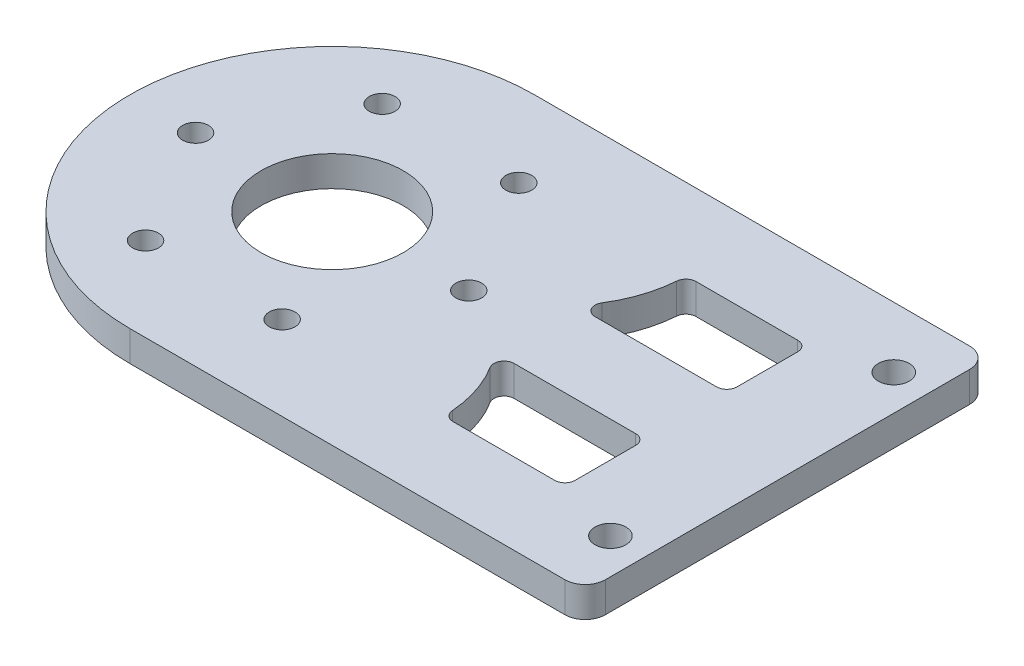
from build123d import *

# Parameters (mm, degrees)
SKETCH_1_R          = 20
SKETCH_1_W          = 45
SKETCH_1_H          = 40
EXTRUDE_1_DEPTH     = 3
SKETCH_3_R          = 1.275
CUT_EXTRUDE_3_DEPTH = 4
SKETCH_6_R          = 7.025
CUT_EXTRUDE_6_DEPTH = 4
FILLET_1_R          = 2
SKETCH_7_R          = 1.525
CUT_EXTRUDE_7_DEPTH = 4
CUT_EXTRUDE_8_DEPTH = 10


with BuildPart() as part:
    # 草图1 → 凸台-拉伸1 (new body)
    with BuildSketch(Plane(origin=(0, 0, 0), x_dir=(1, 0, 0), z_dir=(0, 1, 0))):
        with Locations((-22.5, 0)):
            Circle(SKETCH_1_R)
        Rectangle(SKETCH_1_W, SKETCH_1_H)
    extrude(amount=EXTRUDE_1_DEPTH)

    # 草图3 → 切除-拉伸3 (cut, through all)
    with BuildSketch(Plane(origin=(0, 0, 0), x_dir=(1, 0, 0), z_dir=(0, 1, 0))):
        with Locations((-36, 0)):
            Circle(SKETCH_3_R)
        with Locations((-29.25, 11.691342951)):
            Circle(SKETCH_3_R)
        with Locations((-15.75, 11.691342951)):
            Circle(SKETCH_3_R)
        with Locations((-9, 0)):
            Circle(SKETCH_3_R)
        with Locations((-15.75, -11.691342951)):
            Circle(SKETCH_3_R)
        with Locations((-29.25, -11.691342951)):
            Circle(SKETCH_3_R)
    extrude(amount=CUT_EXTRUDE_3_DEPTH, mode=Mode.SUBTRACT)

    # 草图6 → 切除-拉伸6 (cut, through all)
    with BuildSketch(Plane(origin=(0, 3, 0), x_dir=(1, 0, 0), z_dir=(0, 1, 0))):
        with Locations((-22.5, 0)):
            Circle(SKETCH_6_R)
    extrude(amount=-CUT_EXTRUDE_6_DEPTH, mode=Mode.SUBTRACT)

    # 圆角1
    fillet_1_edges = [part.edges().sort_by_distance(p)[0] for p in [
        (22.5, 1.5, -20),
        (22.5, 1.5, 20),
    ]]
    fillet(fillet_1_edges, radius=FILLET_1_R)

    # 草图7 → 切除-拉伸7 (cut, through all)
    with BuildSketch(Plane(origin=(0, 3, 0), x_dir=(1, 0, 0), z_dir=(0, 1, 0))):
        with Locations((19, -14)):
            Circle(SKETCH_7_R)
        with Locations((19, 14)):
            Circle(SKETCH_7_R)
    extrude(amount=-CUT_EXTRUDE_7_DEPTH, mode=Mode.SUBTRACT)

    # 草图8 → 切除-拉伸8 (cut)
    with BuildSketch(Plane(origin=(0, 3, 0), x_dir=(1, 0, 0), z_dir=(0, 1, 0))):
        with BuildLine():
            Line((-0.51493536, -4.000000002), (11.500000002, -4.000000002))
            ThreePointArc((11.500000002, -4.000000002), (12.207106783, -4.29289322), (12.500000002, -5.000000002))
            Line((12.500000002, -5.000000002), (12.500000002, -11.000000002))
            ThreePointArc((12.500000002, -11.000000002), (12.207106783, -11.707106783), (11.500000002, -12.000000002))
            Line((11.500000002, -12.000000002), (1.461970397, -12.000000002))
            ThreePointArc((1.461970397, -12.000000002), (0.782245955, -11.733467577), (0.464858721, -11.075949369))
            ThreePointArc((0.464858721, -11.075949369), (-0.111079243, -8.192615452), (-1.361902294, -5.531645571))
            ThreePointArc((-1.361902294, -5.531645571), (-1.390048372, -4.516081398), (-0.51493536, -4.000000002))
        make_face()
    cut_extrude_8 = extrude(amount=-CUT_EXTRUDE_8_DEPTH, mode=Mode.SUBTRACT)

    # 镜向1: 切除-拉伸8 across plane
    add(cut_extrude_8.mirror(Plane.XY), mode=Mode.SUBTRACT)


solid = part.part
